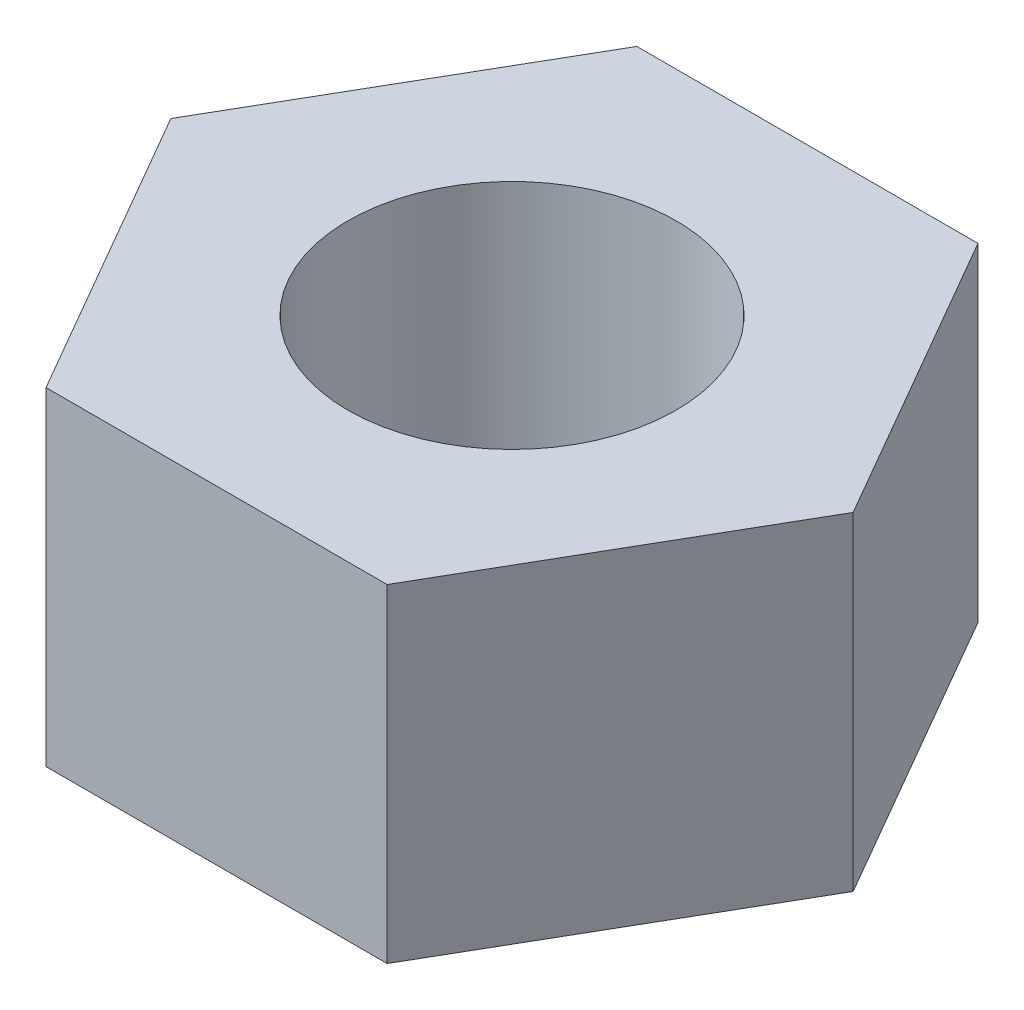
from build123d import *

# Parameters (mm, degrees)
SKETCH2_R           = 4.5
BOSS_EXTRUDE1_DEPTH = 9


with BuildPart() as part:
    # Sketch2 → Boss-Extrude1 (new body)
    with BuildSketch(Plane(origin=(0, 0, 0), x_dir=(1, 0, 0), z_dir=(0, 1, 0))):
        Polygon((4.67653718, 8.1), (-4.67653718, 8.1), (-9.353074361, 0), (-4.67653718, -8.1), (4.67653718, -8.1), (9.353074361, 0), align=None)
        with Locations(Location((0, 0, 0), (0, 0, 270))):  # turned: the seam where the file's is
            Circle(SKETCH2_R, mode=Mode.SUBTRACT)
    extrude(amount=BOSS_EXTRUDE1_DEPTH)


solid = part.part
